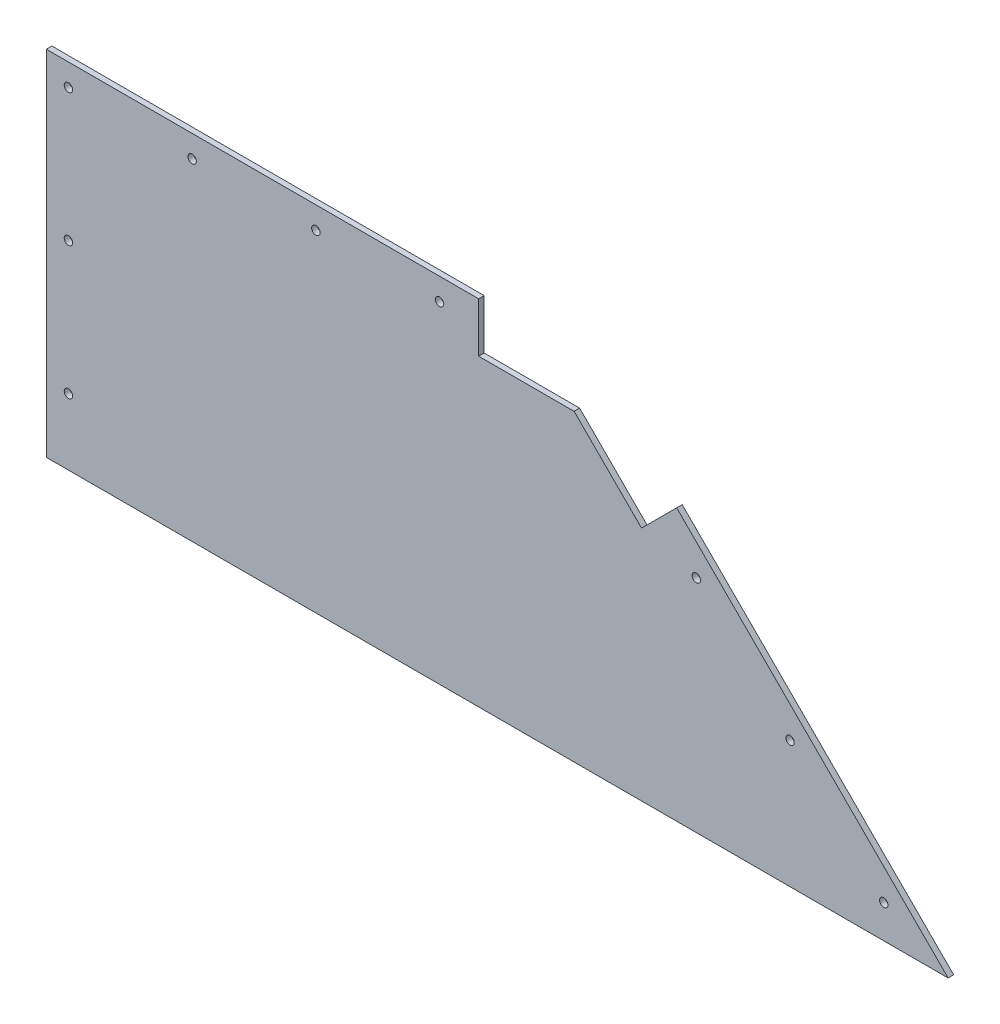
from build123d import *

# Parameters (mm, degrees)
BOSS_EXTRUDE1_DEPTH = 3.175
CUT_EXTRUDE1_REACH  = 5.175
SKETCH2_R           = 2.413
CUT_EXTRUDE2_REACH  = 5.175
SKETCH3_R           = 2.413
CUT_EXTRUDE3_REACH  = 5.175


with BuildPart() as part:
    # Sketch1 → Boss-Extrude1 (new body)
    with BuildSketch(Plane.XY):
        Polygon((315.214, 203.2), (518.414, 0), (127, 0), (0, 0), (0, 203.2), align=None)
    extrude(amount=BOSS_EXTRUDE1_DEPTH)

    # Sketch2 → Cut-Extrude1 (cut, up to next)
    with BuildSketch(Plane.XY.offset(3.175), mode=Mode.PRIVATE) as cut_extrude1_sk1:
        with Locations((12.7, 190.5)):
            Circle(SKETCH2_R)
    cut_extrude1_tool1 = extrude(cut_extrude1_sk1.sketch, amount=-CUT_EXTRUDE1_REACH, mode=Mode.PRIVATE) & part.part
    add(cut_extrude1_tool1.solids().sort_by_distance((12.7, 190.5, 3.175))[0], mode=Mode.SUBTRACT)
    # Sketch2 → Cut-Extrude1 (cut, up to next)
    with BuildSketch(Plane.XY.offset(3.175), mode=Mode.PRIVATE) as cut_extrude1_sk2:
        with Locations((83.82, 190.5)):
            Circle(SKETCH2_R)
    cut_extrude1_tool2 = extrude(cut_extrude1_sk2.sketch, amount=-CUT_EXTRUDE1_REACH, mode=Mode.PRIVATE) & part.part
    add(cut_extrude1_tool2.solids().sort_by_distance((83.82, 190.5, 3.175))[0], mode=Mode.SUBTRACT)
    # Sketch2 → Cut-Extrude1 (cut, up to next)
    with BuildSketch(Plane.XY.offset(3.175), mode=Mode.PRIVATE) as cut_extrude1_sk3:
        with Locations((154.94, 190.5)):
            Circle(SKETCH2_R)
    cut_extrude1_tool3 = extrude(cut_extrude1_sk3.sketch, amount=-CUT_EXTRUDE1_REACH, mode=Mode.PRIVATE) & part.part
    add(cut_extrude1_tool3.solids().sort_by_distance((154.94, 190.5, 3.175))[0], mode=Mode.SUBTRACT)
    # Sketch2 → Cut-Extrude1 (cut, up to next)
    with BuildSketch(Plane.XY.offset(3.175), mode=Mode.PRIVATE) as cut_extrude1_sk4:
        with Locations((226.06, 190.5)):
            Circle(SKETCH2_R)
    cut_extrude1_tool4 = extrude(cut_extrude1_sk4.sketch, amount=-CUT_EXTRUDE1_REACH, mode=Mode.PRIVATE) & part.part
    add(cut_extrude1_tool4.solids().sort_by_distance((226.06, 190.5, 3.175))[0], mode=Mode.SUBTRACT)
    # Sketch2 → Cut-Extrude1 (cut, up to next)
    with BuildSketch(Plane.XY.offset(3.175), mode=Mode.PRIVATE) as cut_extrude1_sk5:
        with Locations((12.7, 114.3)):
            Circle(SKETCH2_R)
    cut_extrude1_tool5 = extrude(cut_extrude1_sk5.sketch, amount=-CUT_EXTRUDE1_REACH, mode=Mode.PRIVATE) & part.part
    add(cut_extrude1_tool5.solids().sort_by_distance((12.7, 114.3, 3.175))[0], mode=Mode.SUBTRACT)
    # Sketch2 → Cut-Extrude1 (cut, up to next)
    with BuildSketch(Plane.XY.offset(3.175), mode=Mode.PRIVATE) as cut_extrude1_sk6:
        with Locations((12.7, 38.1)):
            Circle(SKETCH2_R)
    cut_extrude1_tool6 = extrude(cut_extrude1_sk6.sketch, amount=-CUT_EXTRUDE1_REACH, mode=Mode.PRIVATE) & part.part
    add(cut_extrude1_tool6.solids().sort_by_distance((12.7, 38.1, 3.175))[0], mode=Mode.SUBTRACT)

    # Sketch3 → Cut-Extrude2 (cut, up to next)
    with BuildSketch(Plane.XY.offset(3.175), mode=Mode.PRIVATE) as cut_extrude2_sk1:
        with Locations((481.403487758, 19.05)):
            Circle(SKETCH3_R)
    cut_extrude2_tool1 = extrude(cut_extrude2_sk1.sketch, amount=-CUT_EXTRUDE2_REACH, mode=Mode.PRIVATE) & part.part
    add(cut_extrude2_tool1.solids().sort_by_distance((481.403488, 19.05, 3.175))[0], mode=Mode.SUBTRACT)
    # Sketch3 → Cut-Extrude2 (cut, up to next)
    with BuildSketch(Plane.XY.offset(3.175), mode=Mode.PRIVATE) as cut_extrude2_sk2:
        with Locations((427.521951031, 72.931536726)):
            Circle(SKETCH3_R)
    cut_extrude2_tool2 = extrude(cut_extrude2_sk2.sketch, amount=-CUT_EXTRUDE2_REACH, mode=Mode.PRIVATE) & part.part
    add(cut_extrude2_tool2.solids().sort_by_distance((427.521951, 72.931537, 3.175))[0], mode=Mode.SUBTRACT)
    # Sketch3 → Cut-Extrude2 (cut, up to next)
    with BuildSketch(Plane.XY.offset(3.175), mode=Mode.PRIVATE) as cut_extrude2_sk3:
        with Locations((373.640414305, 126.813073453)):
            Circle(SKETCH3_R)
    cut_extrude2_tool3 = extrude(cut_extrude2_sk3.sketch, amount=-CUT_EXTRUDE2_REACH, mode=Mode.PRIVATE) & part.part
    add(cut_extrude2_tool3.solids().sort_by_distance((373.640414, 126.813073, 3.175))[0], mode=Mode.SUBTRACT)
    # Sketch3 → Cut-Extrude2 (cut, up to next)
    with BuildSketch(Plane.XY.offset(3.175), mode=Mode.PRIVATE) as cut_extrude2_sk4:
        with Locations((319.758877579, 180.694610179)):
            Circle(SKETCH3_R)
    cut_extrude2_tool4 = extrude(cut_extrude2_sk4.sketch, amount=-CUT_EXTRUDE2_REACH, mode=Mode.PRIVATE) & part.part
    add(cut_extrude2_tool4.solids().sort_by_distance((319.758878, 180.69461, 3.175))[0], mode=Mode.SUBTRACT)

    # Sketch4 → Cut-Extrude3 (cut, up to next)
    with BuildSketch(Plane.XY.offset(3.175), mode=Mode.PRIVATE) as cut_extrude3_sk1:
        Polygon((315.214, 203.2), (248.539, 203.2), (248.539, 174.625), (303.377847455, 174.625), (342.154768363, 135.848079092), (362.360344636, 156.053655364), align=None)
    cut_extrude3_tool1 = extrude(cut_extrude3_sk1.sketch, amount=-CUT_EXTRUDE3_REACH, mode=Mode.PRIVATE) & part.part
    add(cut_extrude3_tool1.solids().sort_by_distance((305.025183, 178.602019, 3.175))[0], mode=Mode.SUBTRACT)


solid = part.part
